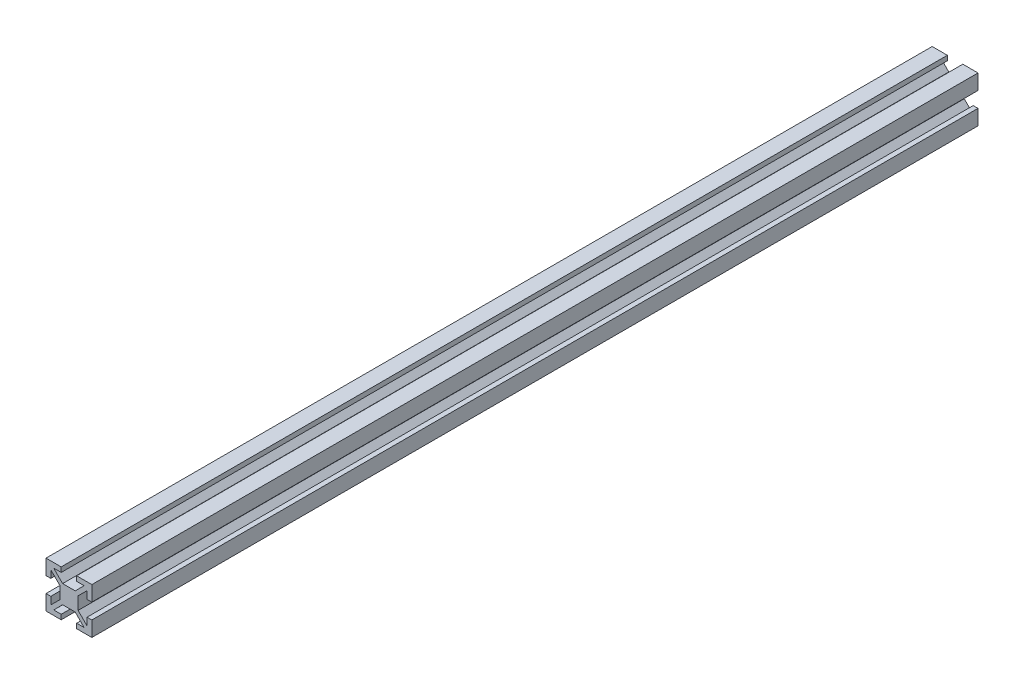
from build123d import *

# Parameters (mm, degrees)
BOSS_EXTRUDE1_DEPTH = 145


with BuildPart() as part:
    # Sketch1 → Boss-Extrude1 (new body, symmetric)
    with BuildSketch(Plane.XY):
        Polygon((-7.5, 7.5), (-2.530730605, 7.5), (-2.530730605, 5.924492669), (-4.971633189, 5.924492669), (-2.069295768, 3), (2.069295768, 3), (4.971633189, 5.924492669), (2.530730605, 5.924492669), (2.530730605, 7.5), (7.5, 7.5), (7.5, 2.530730605), (5.924492669, 2.530730605), (5.924492669, 4.971633189), (3, 2.069295768), (3, -2.069295768), (5.924492669, -4.971633189), (5.924492669, -2.530730605), (7.5, -2.530730605), (7.5, -7.5), (2.530730605, -7.5), (2.530730605, -5.924492669), (4.971633189, -5.924492669), (2.069295768, -3), (-2.069295768, -3), (-4.971633189, -5.924492669), (-2.530730605, -5.924492669), (-2.530730605, -7.5), (-7.5, -7.5), (-7.5, -2.530730605), (-5.924492669, -2.530730605), (-5.924492669, -4.971633189), (-3, -2.069295768), (-3, 2.069295768), (-5.924492669, 4.971633189), (-5.924492669, 2.530730605), (-7.5, 2.530730605), align=None)
    extrude(amount=BOSS_EXTRUDE1_DEPTH, both=True)


solid = part.part
